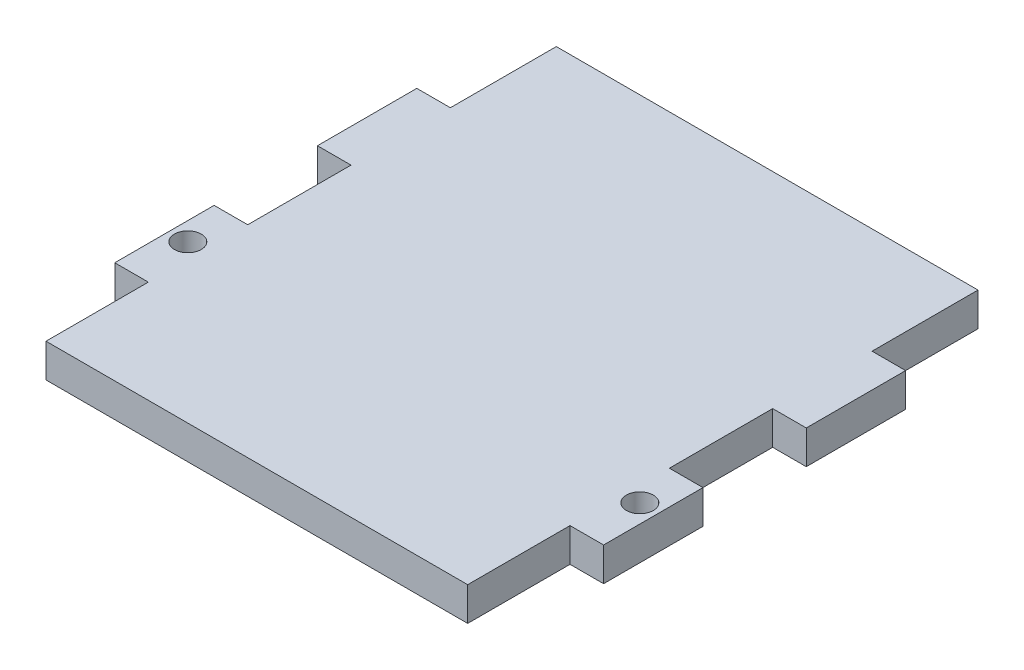
from build123d import *

# Parameters (mm, degrees)
SKETCH1_R           = 2.54
BOSS_EXTRUDE1_DEPTH = 6.35


with BuildPart() as part:
    # Sketch1 → Boss-Extrude1 (new body)
    with BuildSketch(Plane(origin=(0, 0, 0), x_dir=(1, 0, 0), z_dir=(0, 1, 0))):
        Polygon((39.688377001, 96.236406132), (39.688377001, 76.199995009), (46.038377001, 76.199995009), (46.038377001, 57.403995009), (39.688377001, 57.403995009), (39.688377001, 37.867206132), (46.038377001, 37.867206132), (46.038377001, 19.071206132), (39.688377001, 19.071206132), (39.688377001, -0.283593868), (-40.067622999, -0.283593868), (-40.067622999, 19.071206132), (-46.417622999, 19.071206132), (-46.417622999, 37.867206132), (-40.067622999, 37.867206132), (-40.067622999, 57.403995009), (-46.417622999, 57.403995009), (-46.417622999, 76.199995009), (-40.067622999, 76.199995009), (-40.067622999, 96.236406132), align=None)
        with Locations((42.559284822, 29.410565998)):
            Circle(SKETCH1_R, mode=Mode.SUBTRACT)
        with Locations((-42.93853082, 29.410565998)):
            Circle(SKETCH1_R, mode=Mode.SUBTRACT)
    extrude(amount=BOSS_EXTRUDE1_DEPTH)


solid = part.part
